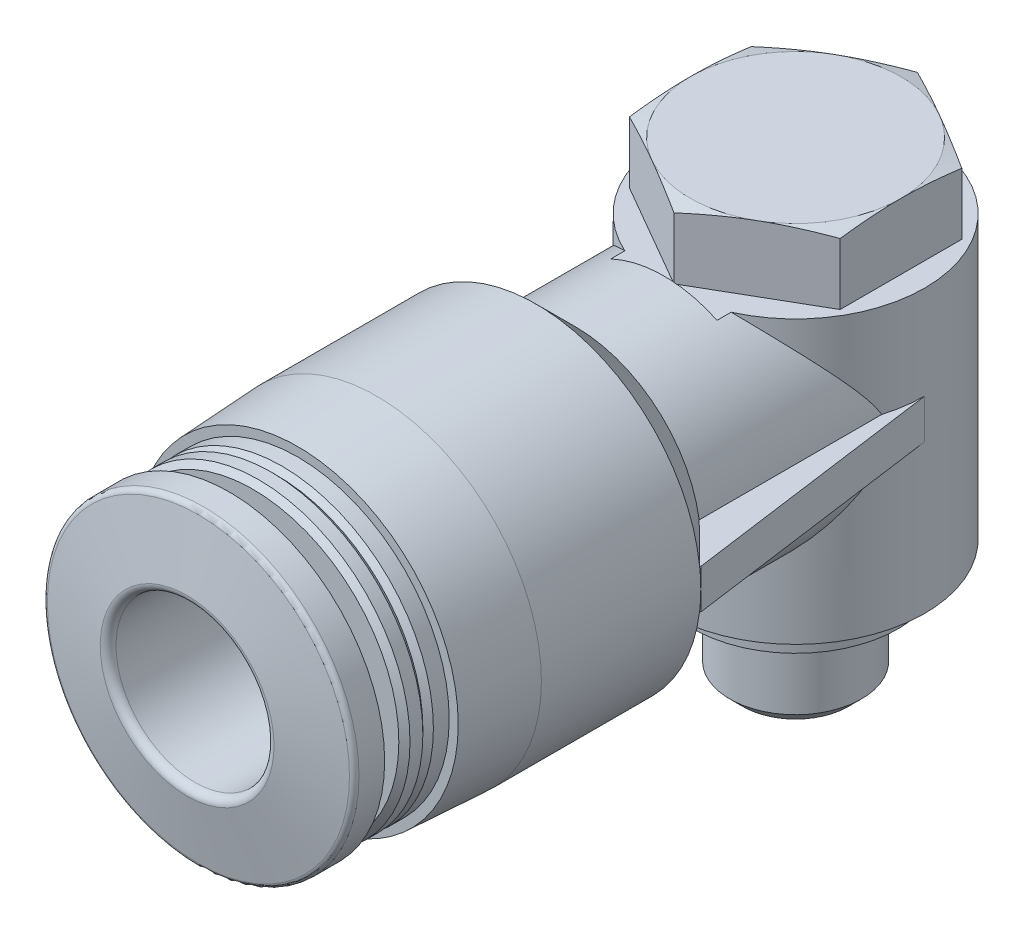
from build123d import *

# Parameters (mm, degrees)
LINEAR_AUSTRAGEN1_DEPTH      = 0.75
LINEAR_AUSTRAGEN1_DEPTH_BACK = 0.75
SKIZZE5_W                    = 16
SKIZZE5_H                    = 16
LINEAR_AUSTRAGEN2_DEPTH      = 2.5
SKIZZE6_W                    = 0.8
SKIZZE6_H                    = 10.9


with BuildPart() as part:
    # Skizze1 → Rotation1 (revolve)
    with BuildSketch(Plane(origin=(0, 0, 0), x_dir=(0, 0, -1), z_dir=(1, 0, 0))):
        Polygon((0, 6.8), (4, 6.8), (4.9, 6.558845727), (4.9, -6.4), (3.4, -6.4), (3.4, -6.9), (3.9, -6.9), (3.9, -7.4), (2.5, -7.4), (2.5, -10.4095), (2.0095, -10.9), (0, -10.9), align=None)
    revolve(axis=Axis((0, -10.9, 0), (0, 1, 0)))

    # Skizze2 → Rotation2 (revolve)
    with BuildSketch(Plane(origin=(0, 0, 0), x_dir=(0, 0, -1), z_dir=(1, 0, 0))):
        with BuildLine():
            Line((0, -4.75), (-8.35, -4.75))
            Line((-8.35, -4.75), (-9.85, -6.25))
            Line((-9.85, -6.25), (-15.9, -6.25))
            Line((-15.9, -6.25), (-18.9, -6.092776662))
            Line((-18.9, -6.092776662), (-18.9, -5.75))
            Line((-18.9, -5.75), (-19.5, -5.75))
            Line((-19.5, -5.75), (-19.7, -5.55))
            Line((-19.7, -5.55), (-19.9, -5.75))
            Line((-19.9, -5.75), (-20.387867966, -5.75))
            Line((-20.387867966, -5.75), (-20.6, -5.537867966))
            Line((-20.6, -5.537867966), (-20.6, -4.05))
            Line((-20.6, -4.05), (-21.3, -4.05))
            ThreePointArc((-21.3, -4.05), (-21.441421356, -4.108578644), (-21.5, -4.25))
            Line((-21.5, -4.25), (-21.5, -5.9))
            Line((-21.5, -5.9), (-22.473729924, -5.9))
            ThreePointArc((-22.473729924, -5.9), (-22.602287446, -5.853208889), (-22.670691475, -5.734729636))
            Line((-22.670691475, -5.734729636), (-23.1, -3.3))
            Line((-23.1, -3.3), (-23.1, 0))
            Line((-23.1, 0), (4.75, 0))
            ThreePointArc((4.75, 0), (3.358757211, -3.358757211), (0, -4.75))
        make_face()
    revolve(axis=Axis((0, 0, 23.1), (0, 0, -1)))

    # Skizze4 → Linear austragen1 (add, two sides: drawn at the far end of the back side and taken through both)
    with BuildSketch(Plane(origin=(0, 0, 0), x_dir=(1, 0, 0), z_dir=(0, 1, 0)).offset(-LINEAR_AUSTRAGEN1_DEPTH_BACK)):
        Polygon((-6.25, -9.85), (6.25, -9.85), (4.9, 0), (-4.9, 0), align=None)
    extrude(amount=LINEAR_AUSTRAGEN1_DEPTH + LINEAR_AUSTRAGEN1_DEPTH_BACK)

    # Skizze5 → Linear austragen2 (cut)
    with BuildSketch(Plane(origin=(0, 4.3, 0), x_dir=(-1, 0, 0), z_dir=(0, 1, 0))):
        with Locations((0, -3)):
            Rectangle(SKIZZE5_W, SKIZZE5_H)
        Polygon((4, 2.309401077), (0, 4.618802154), (-4, 2.309401077), (-4, -2.309401077), (0, -4.618802154), (4, -2.309401077), align=None, mode=Mode.SUBTRACT)
    extrude(amount=LINEAR_AUSTRAGEN2_DEPTH, mode=Mode.SUBTRACT)

    # Skizze6 → Schnitt-Rotation1 (revolve, cut)
    with BuildSketch(Plane(origin=(0, 0, 0), x_dir=(0, 0, -1), z_dir=(1, 0, 0))):
        with Locations((0.4, -5.45)):
            Rectangle(SKIZZE6_W, SKIZZE6_H)
    revolve(axis=Axis((0, -10.9, 0), (0, 1, 0)), mode=Mode.SUBTRACT)

    # Skizze3 → Schnitt-Rotation2 (revolve, cut)
    with BuildSketch(Plane(origin=(0, 0, 0), x_dir=(0, 0, -1), z_dir=(1, 0, 0))):
        with BuildLine():
            Line((0, -0.8), (-6.1, -0.8))
            Line((-6.1, -0.8), (-6.1, -3))
            Line((-6.1, -3), (-22.8, -3))
            ThreePointArc((-22.8, -3), (-23.012132034, -3.087867966), (-23.1, -3.3))
            Line((-23.1, -3.3), (-23.1, 0))
            Line((-23.1, 0), (0.8, 0))
            ThreePointArc((0.8, 0), (0.565685425, -0.565685425), (0, -0.8))
        make_face()
    revolve(axis=Axis((0, 0, 23.1), (0, 0, -1)), mode=Mode.SUBTRACT)


solid = part.part
